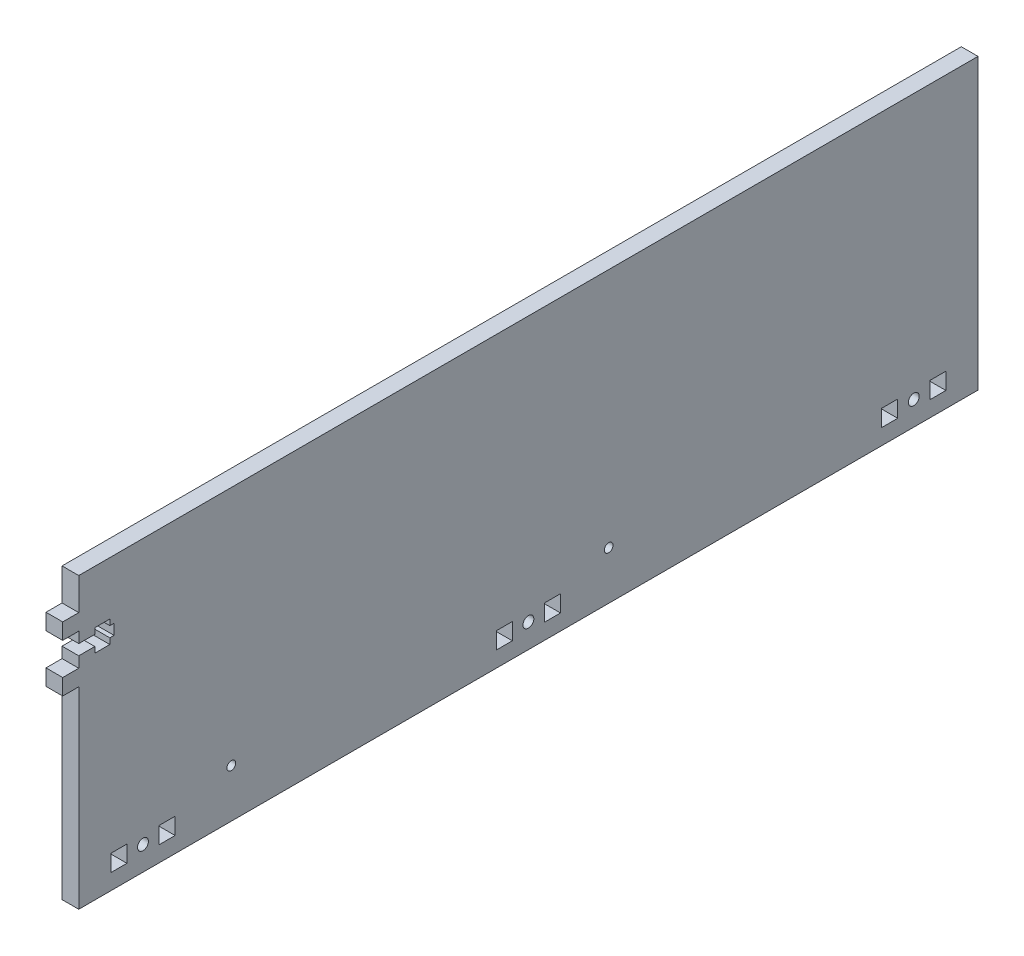
from build123d import *

# Parameters (mm, degrees)
SKETCH1_W                                         = 355.6
SKETCH1_H                                         = 114.3
SKETCH1_R                                         = 2.15265
SKETCH1_W_2                                       = 6.35
SKETCH1_H_2                                       = 6.604
BOSS_EXTRUDE1_DEPTH                               = 6.604
CUT_EXTRUDE1_DEPTH                                = 7.604
SKETCH6_W                                         = 6.35
SKETCH6_H                                         = 6.35
BOSS_EXTRUDE2_DEPTH                               = 6.604
CSK_FOR_8_FLAT_HEAD_SOCKET_CAP_SCREW1_D           = 4.3053
CSK_FOR_8_FLAT_HEAD_SOCKET_CAP_SCREW1_CSINK_D     = 9.1186
CSK_FOR_8_FLAT_HEAD_SOCKET_CAP_SCREW1_CSINK_ANGLE = 82
F_8_32_TAPPED_HOLE1_D                             = 3.4544
F_8_32_TAPPED_HOLE1_DEPTH                         = 10.7188
F_8_32_TAPPED_HOLE1_TIP                           = 1.037806461


with BuildPart() as part:
    # Sketch1 → Boss-Extrude1 (new body)
    with BuildSketch(Plane(origin=(0, 0, 0), x_dir=(0, 0, -1), z_dir=(1, 0, 0))):
        with Locations((0, 57.15)):
            Rectangle(SKETCH1_W, SKETCH1_H)
        with Locations((-152.4, 9.525)):
            Circle(SKETCH1_R, mode=Mode.SUBTRACT)
        with Locations((0, 9.525)):
            Circle(SKETCH1_R, mode=Mode.SUBTRACT)
        with Locations((152.4, 9.525)):
            Circle(SKETCH1_R, mode=Mode.SUBTRACT)
        with Locations((-142.875, 9.525)):
            Rectangle(SKETCH1_W_2, SKETCH1_H_2, mode=Mode.SUBTRACT)
        with Locations((-161.925, 9.525)):
            Rectangle(SKETCH1_W_2, SKETCH1_H_2, mode=Mode.SUBTRACT)
        with Locations((9.525, 9.525)):
            Rectangle(SKETCH1_W_2, SKETCH1_H_2, mode=Mode.SUBTRACT)
        with Locations((-9.525, 9.525)):
            Rectangle(SKETCH1_W_2, SKETCH1_H_2, mode=Mode.SUBTRACT)
        with Locations((161.925, 9.525)):
            Rectangle(SKETCH1_W_2, SKETCH1_H_2, mode=Mode.SUBTRACT)
        with Locations((142.875, 9.525)):
            Rectangle(SKETCH1_W_2, SKETCH1_H_2, mode=Mode.SUBTRACT)
    extrude(amount=BOSS_EXTRUDE1_DEPTH)

    # Sketch5 → Cut-Extrude1 (cut, through all)
    with BuildSketch(Plane.ZY):
        Polygon((177.8, 90.9828), (171.45, 90.9828), (171.45, 93.2688), (165.5064, 93.2688), (165.5064, 90.9828), (163.83, 90.9828), (163.83, 86.8172), (165.5064, 86.8172), (165.5064, 84.5312), (171.45, 84.5312), (171.45, 86.8172), (177.8, 86.8172), align=None)
    extrude(amount=-CUT_EXTRUDE1_DEPTH, mode=Mode.SUBTRACT)

    # Sketch6 → Boss-Extrude2 (add)
    with BuildSketch(Plane.ZY):
        with Locations((180.975, 98.425)):
            Rectangle(SKETCH6_W, SKETCH6_H)
        with Locations((180.975, 79.375)):
            Rectangle(SKETCH6_W, SKETCH6_H)
    extrude(amount=-BOSS_EXTRUDE2_DEPTH)

    # CSK for #8 Flat Head Socket Cap Screw1 (through all)
    with Locations(Plane.ZY):
        with Locations((-152.4, 9.525), (0, 9.525), (152.4, 9.525)):
            CounterSinkHole(CSK_FOR_8_FLAT_HEAD_SOCKET_CAP_SCREW1_D / 2, CSK_FOR_8_FLAT_HEAD_SOCKET_CAP_SCREW1_CSINK_D / 2, counter_sink_angle=CSK_FOR_8_FLAT_HEAD_SOCKET_CAP_SCREW1_CSINK_ANGLE)

    # #8-32 Tapped Hole1
    with Locations(Plane.ZY):
        with Locations((117.475, 19.05), (-31.75, 19.05)):
            Hole(F_8_32_TAPPED_HOLE1_D / 2, depth=F_8_32_TAPPED_HOLE1_DEPTH)
            with Locations((0, 0, -(F_8_32_TAPPED_HOLE1_DEPTH + F_8_32_TAPPED_HOLE1_TIP / 2))):  # 118° drill point
                Cone(0, F_8_32_TAPPED_HOLE1_D / 2, F_8_32_TAPPED_HOLE1_TIP, mode=Mode.SUBTRACT)


solid = part.part
